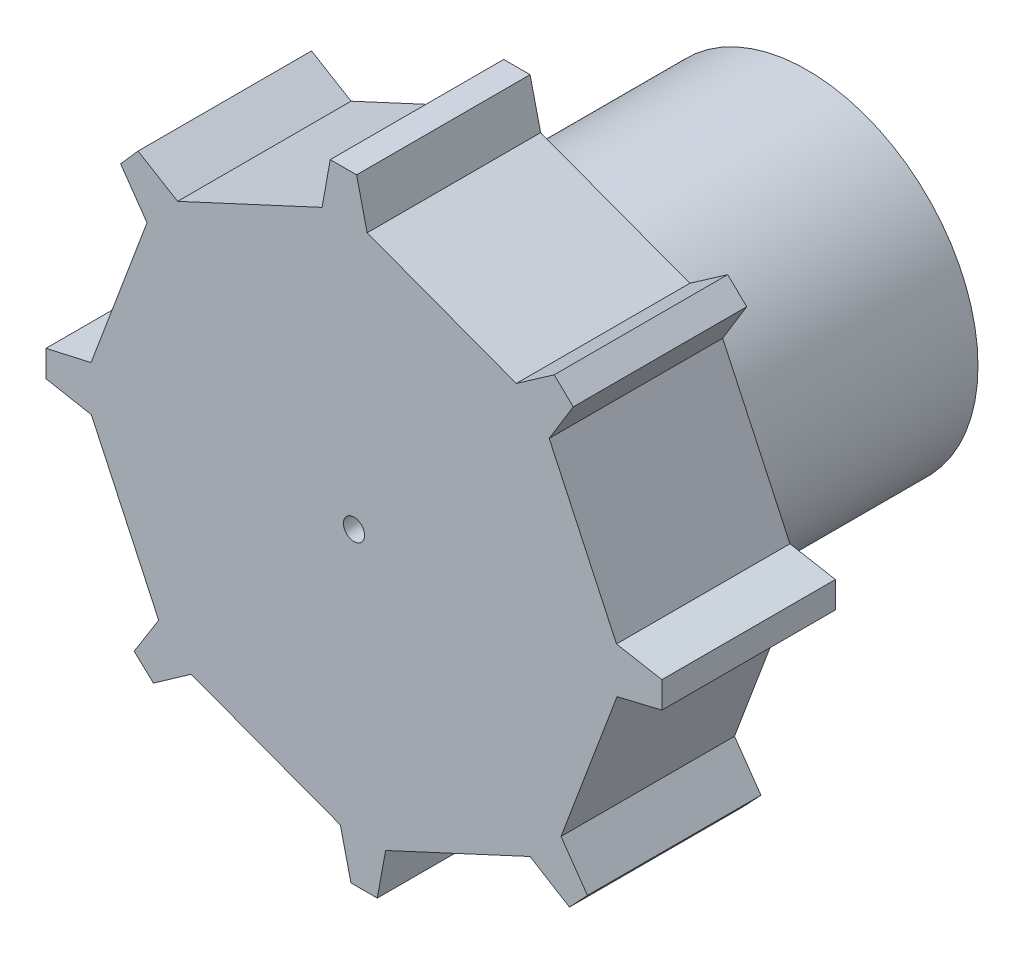
from build123d import *

# Parameters (mm, degrees)
BOSS_EXTRUDE1_DEPTH = 12.7
CUT_EXTRUDE1_REACH  = 14.7
SKETCH2_R           = 0.775
SKETCH4_R           = 12.5
SKETCH4_R_2         = 2.6
BOSS_EXTRUDE3_DEPTH = 20.5


with BuildPart() as part:
    # Sketch1 → Boss-Extrude1 (new body)
    with BuildSketch(Plane(origin=(0, 0, 0), x_dir=(-1, 0, 0), z_dir=(0, 0, -1))):
        Polygon((22.52557458, -1.736588639), (22.52557458, 0.194536921), (19.229808022, 0.93665661), (15.128723263, 11.851737372), (17.063649078, 14.621011813), (15.786423571, 16.069438867), (12.890863827, 14.329165151), (2.313040546, 19.235032954), (1.719665356, 22.560799741), (-0.211460204, 22.560799741), (-0.98374926, 19.271971918), (-11.902473648, 15.180597821), (-14.673902719, 17.112436257), (-16.073066924, 15.781427071), (-14.308800518, 12.900423272), (-19.236913758, 2.332945609), (-22.560976284, 1.730096406), (-22.560976284, -0.201029153), (-19.275488766, -0.987407309), (-15.174404006, -11.902488071), (-17.112216048, -14.669743631), (-15.788139908, -16.075470597), (-12.910837913, -14.305173427), (-2.333014633, -19.21104123), (-1.727718406, -22.534659035), (0.203407153, -22.534659035), (0.978499423, -19.246490729), (11.89722381, -15.155116632), (14.659649692, -17.099807376), (16.072878525, -15.783741196), (14.276312796, -12.922767512), (19.204426036, -2.355289849), align=None)
    extrude(amount=-BOSS_EXTRUDE1_DEPTH)

    # Sketch2 → Cut-Extrude1 (cut, up to next)
    with BuildSketch(Plane(origin=(0, 0, 0), x_dir=(-1, 0, 0), z_dir=(0, 0, -1)), mode=Mode.PRIVATE) as cut_extrude1_sk1:
        with Locations((-0.019773646, -0.00956531)):
            Circle(SKETCH2_R)
    cut_extrude1_tool1 = extrude(cut_extrude1_sk1.sketch, amount=-CUT_EXTRUDE1_REACH, mode=Mode.PRIVATE) & part.part
    add(cut_extrude1_tool1.solids().sort_by_distance((0.019774, -0.009565, 0))[0], mode=Mode.SUBTRACT)

    # Sketch4 → Boss-Extrude3 (add)
    with BuildSketch(Plane(origin=(0, 0, 0), x_dir=(-1, 0, 0), z_dir=(0, 0, -1))):
        Circle(SKETCH4_R)
        Circle(SKETCH4_R_2, mode=Mode.SUBTRACT)
    extrude(amount=BOSS_EXTRUDE3_DEPTH)


solid = part.part
